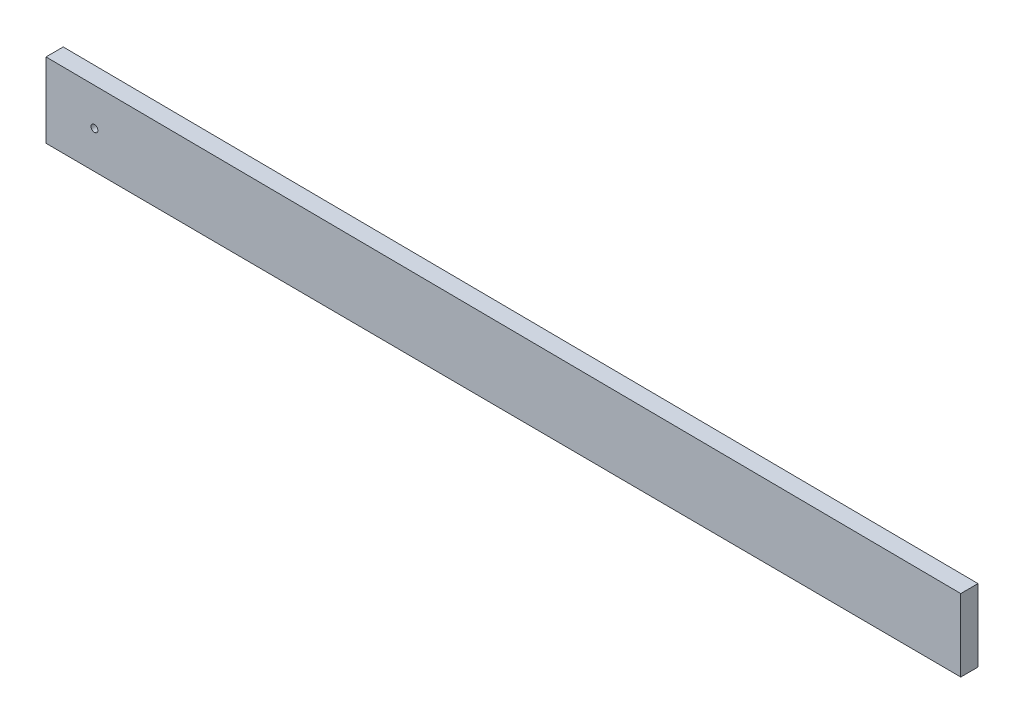
from build123d import *

# Parameters (mm, degrees)
SKETCH1_R           = 0.635
BOSS_EXTRUDE1_DEPTH = 3.175


with BuildPart() as part:
    # Sketch1 → Boss-Extrude1 (new body)
    with BuildSketch(Plane.XY):
        Polygon((1.5875, 128.192969627), (1.5875, 141.955116052), (169.8625, 140.597136541), (169.8625, 127.291804233), align=None)
        with Locations((10.495441348, 135.01829257)):
            Circle(SKETCH1_R, mode=Mode.SUBTRACT)
    extrude(amount=-BOSS_EXTRUDE1_DEPTH)


solid = part.part
